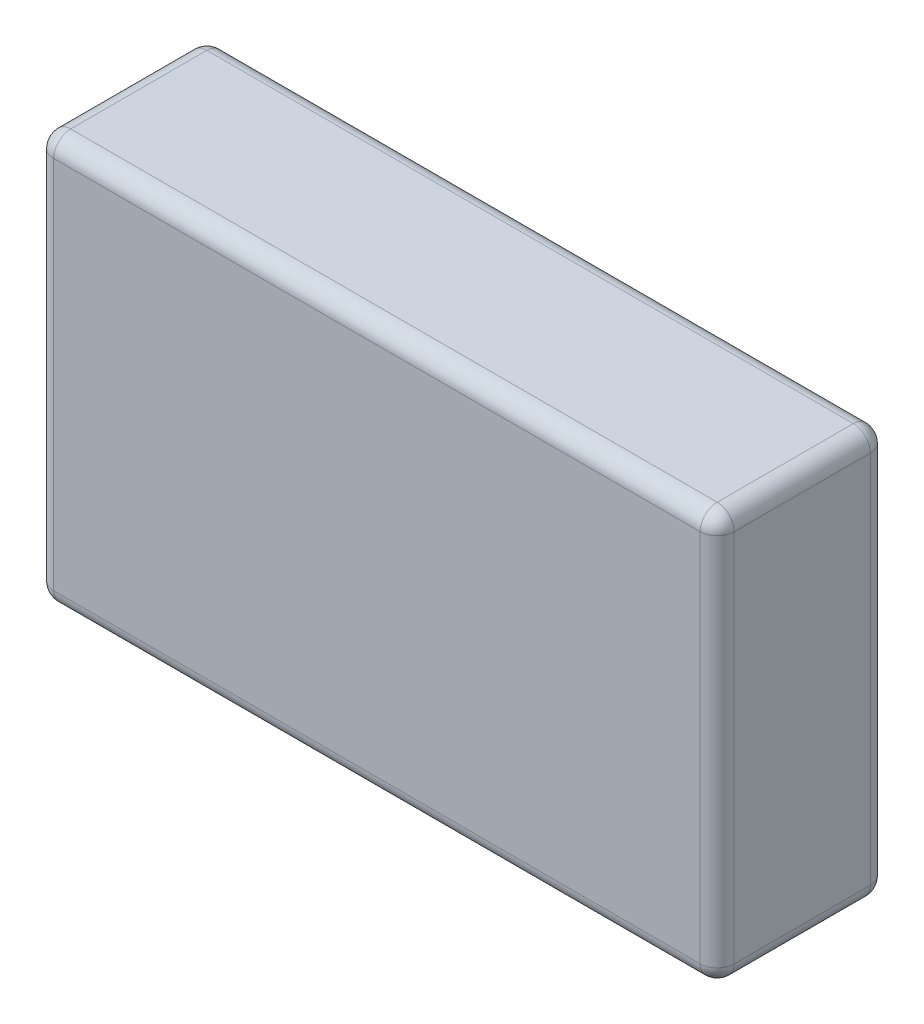
from build123d import *

# Parameters (mm, degrees)
SKETCH_1_W      = 20
SKETCH_1_H      = 12
EXTRUDE_1_DEPTH = 5
FILLET_1_R      = 0.5


with BuildPart() as part:
    # ｽｹｯﾁ1 → ﾎﾞｽ - 押し出し1 (new body)
    with BuildSketch(Plane.XY):
        Rectangle(SKETCH_1_W, SKETCH_1_H)
    extrude(amount=EXTRUDE_1_DEPTH)

    # ﾌｨﾚｯﾄ1
    fillet_1_edges = [part.edges().sort_by_distance(p)[0] for p in [
        (-10, 0, 5),
        (0, -6, 5),
        (10, 0, 5),
        (0, -6, 0),
        (-10, 0, 0),
        (0, 6, 0),
        (10, 0, 0),
        (0, 6, 5),
        (10, -6, 2.5),
        (-10, -6, 2.5),
        (-10, 6, 2.5),
        (10, 6, 2.5),
    ]]
    fillet(fillet_1_edges, radius=FILLET_1_R)


solid = part.part
